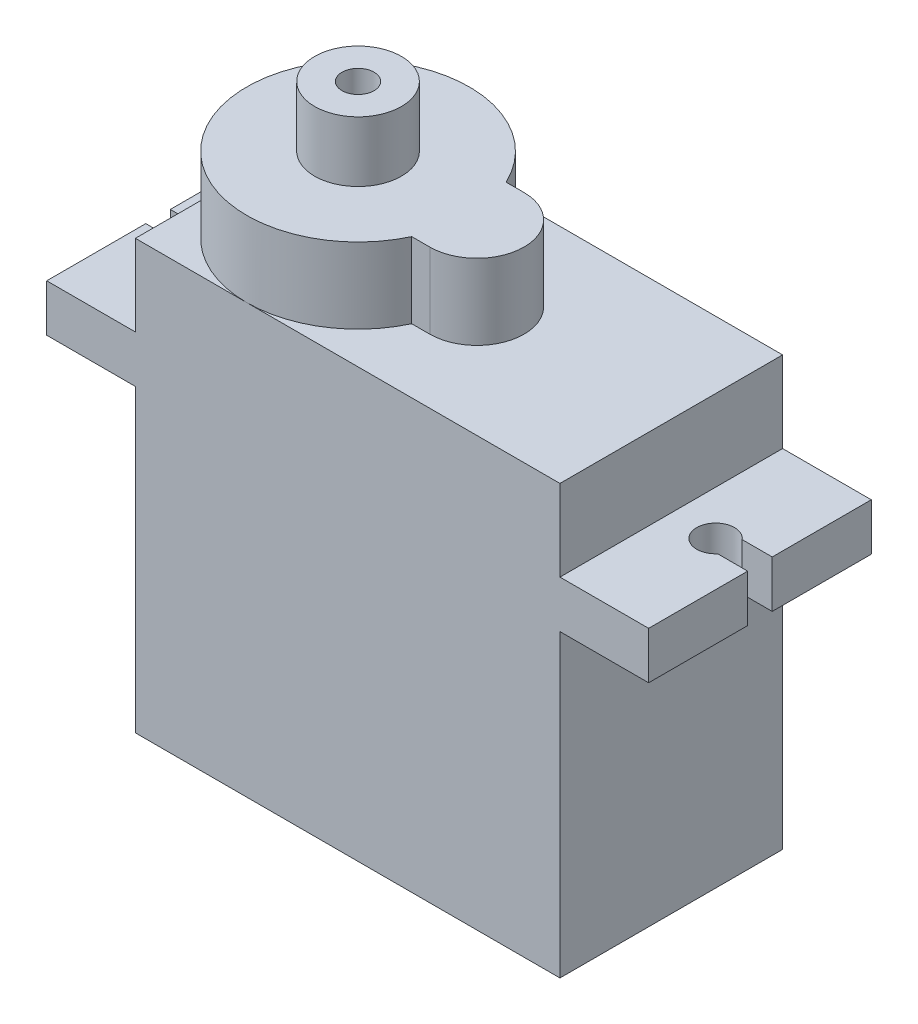
from build123d import *

# Parameters (mm, degrees)
SKETCH1_W           = 22.5
SKETCH1_H           = 11.8
BOSS_EXTRUDE1_DEPTH = 22.7
SKETCH2_W           = 4.7
SKETCH2_H           = 11.8
BOSS_EXTRUDE2_DEPTH = 2.5
BOSS_EXTRUDE3_DEPTH = 4
CUT_EXTRUDE1_DEPTH  = 2.5
SKETCH5_R           = 2.3
SKETCH5_R_2         = 0.85
BOSS_EXTRUDE4_DEPTH = 3.2


with BuildPart() as part:
    # Sketch1 → Boss-Extrude1 (new body)
    with BuildSketch(Plane(origin=(0, 0, 0), x_dir=(1, 0, 0), z_dir=(0, 1, 0))):
        with Locations((11.25, 5.9)):
            Rectangle(SKETCH1_W, SKETCH1_H)
    extrude(amount=BOSS_EXTRUDE1_DEPTH)

    # Sketch2 → Boss-Extrude2 (add)
    with BuildSketch(Plane(origin=(0, 15.89999995, 0), x_dir=(-1, 0, 0), z_dir=(0, -1, 0))):
        with Locations((-24.85, 5.9)):
            Rectangle(SKETCH2_W, SKETCH2_H)
        with Locations((2.35, 5.9)):
            Rectangle(SKETCH2_W, SKETCH2_H)
    extrude(amount=-BOSS_EXTRUDE2_DEPTH)

    # Sketch3 → Boss-Extrude3 (add)
    with BuildSketch(Plane(origin=(0, 22.7, 0), x_dir=(1, 0, 0), z_dir=(0, 1, 0))):
        with BuildLine():
            Line((12.2, 8.4), (11.244155686, 8.4))
            ThreePointArc((11.244155686, 8.4), (0, 5.9), (11.244155686, 3.4))
            Line((11.244155686, 3.4), (12.2, 3.4))
            ThreePointArc((12.2, 3.4), (14.7, 5.9), (12.2, 8.4))
        make_face()
    extrude(amount=BOSS_EXTRUDE3_DEPTH)

    # Sketch4 → Cut-Extrude1 (cut)
    with BuildSketch(Plane(origin=(0, 18.39999995, 0), x_dir=(1, 0, 0), z_dir=(0, 1, 0))):
        with BuildLine():
            Line((-4.7, 6.55), (-4.7, 5.25))
            Line((-4.7, 5.25), (-3.109934208, 5.25))
            ThreePointArc((-3.109934208, 5.25), (-1.35, 5.9), (-3.109934208, 6.55))
            Line((-3.109934208, 6.55), (-4.7, 6.55))
        make_face()
        with BuildLine():
            Line((27.2, 6.55), (27.2, 5.25))
            Line((27.2, 5.25), (25.609934208, 5.25))
            ThreePointArc((25.609934208, 5.25), (23.85, 5.9), (25.609934208, 6.55))
            Line((25.609934208, 6.55), (27.2, 6.55))
        make_face()
    extrude(amount=-CUT_EXTRUDE1_DEPTH, mode=Mode.SUBTRACT)

    # Sketch5 → Boss-Extrude4 (add)
    with BuildSketch(Plane(origin=(0, 26.7, 0), x_dir=(1, 0, 0), z_dir=(0, 1, 0))):
        with Locations((5.9, 5.9)):
            Circle(SKETCH5_R)
        with Locations((5.9, 5.9)):
            Circle(SKETCH5_R_2, mode=Mode.SUBTRACT)
    extrude(amount=BOSS_EXTRUDE4_DEPTH)


solid = part.part
